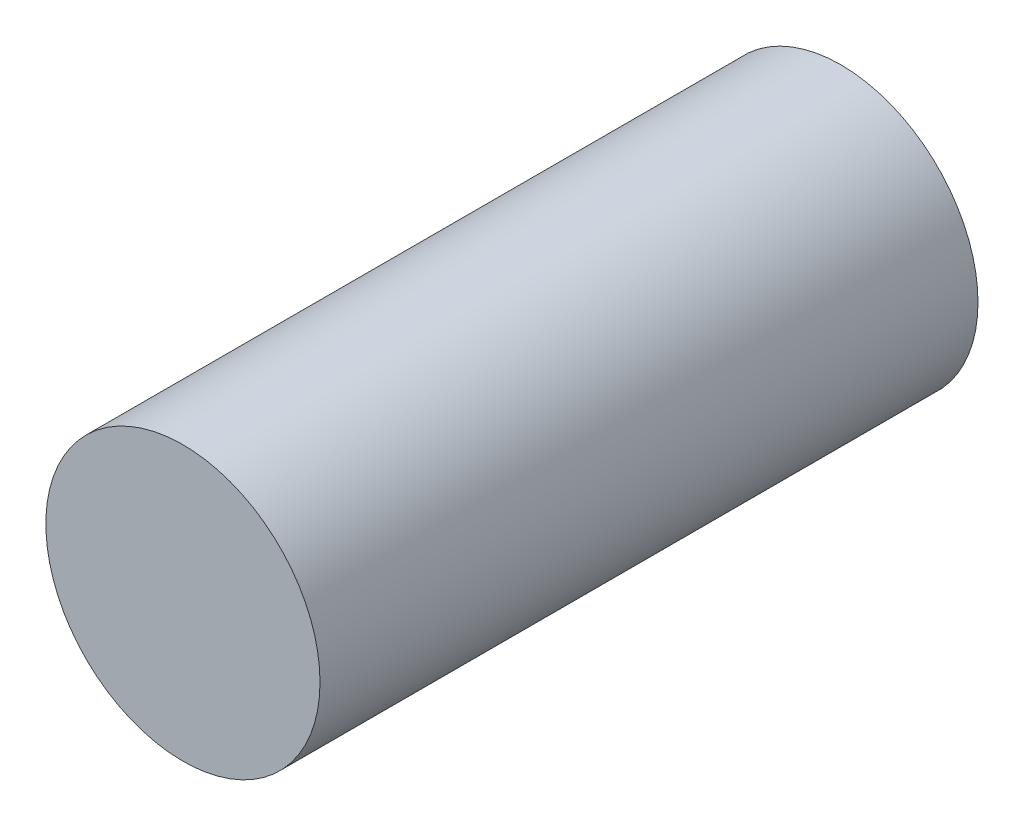
from build123d import *

# Parameters (mm, degrees)
SKETCH1_R                = 3.75
BOSS_EXTRUDE1_DEPTH      = 17
BOSS_EXTRUDE1_DEPTH_BACK = 1


with BuildPart() as part:
    # Sketch1 → Boss-Extrude1 (new body, two sides)
    with BuildSketch(Plane.XY.offset(-6)) as boss_extrude1_sk:
        with Locations((28, 7.3)):
            Circle(SKETCH1_R)
    extrude(amount=BOSS_EXTRUDE1_DEPTH)
    extrude(boss_extrude1_sk.sketch, amount=-BOSS_EXTRUDE1_DEPTH_BACK)


solid = part.part
